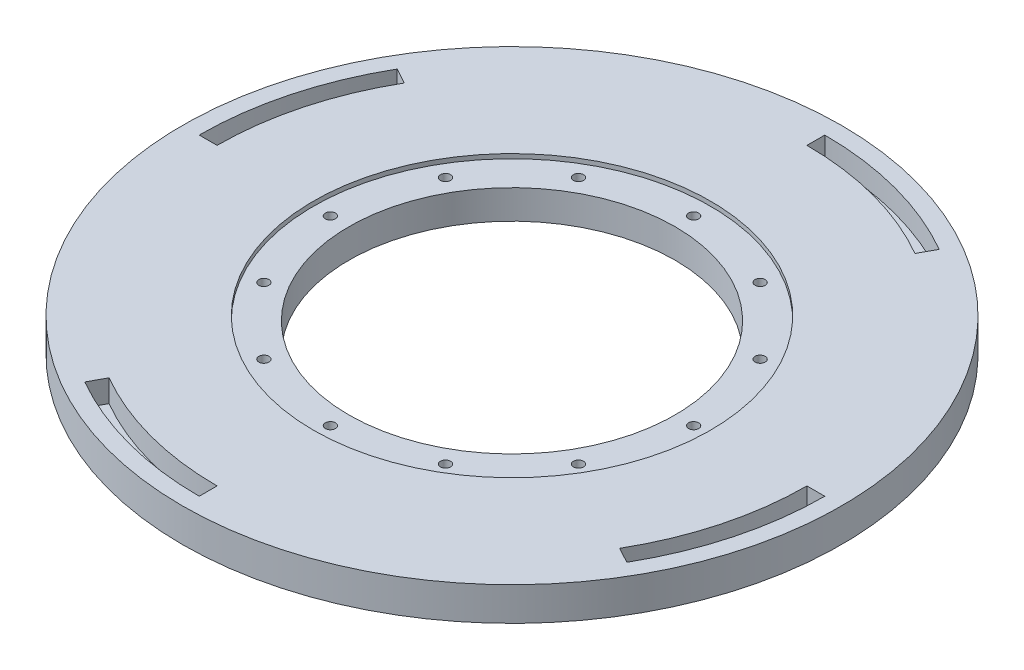
from build123d import *

# Parameters (mm, degrees)
SKETCH1_W                   = 127.635
SKETCH1_H                   = 127.635
BOSS_EXTRUDE1_DEPTH         = 9.525
SKETCH13_R                  = 93.6625
BOSS_EXTRUDE2_DEPTH         = 9.525
SKETCH5_R                   = 46.355
CUT_EXTRUDE1_DEPTH          = 9.525
SKETCH11_R                  = 1.4351
CUT_EXTRUDE3_DEPTH          = 10.525
CIRPATTERN1_COUNT           = 12
SKETCH12_R                  = 56.41975
CUT_EXTRUDE4_DEPTH          = 1.27
SUPPORT_HOLE_DEPTH          = 6.35
SKETCH16_R                  = 1.27
FRAME_BOLT_HOLE_DEPTH       = 3.175
FRAME_SUPPORT_PATTERN_COUNT = 4


with BuildPart() as part:
    # Sketch1 → Boss-Extrude1 (new body)
    with BuildSketch(Plane(origin=(0, 0, 0), x_dir=(1, 0, 0), z_dir=(0, 1, 0))):
        with Locations((63.8175, 63.8175)):
            Rectangle(SKETCH1_W, SKETCH1_H)
    extrude(amount=BOSS_EXTRUDE1_DEPTH)

    # Sketch13 → Boss-Extrude2 (add)
    with BuildSketch(Plane(origin=(0, 9.525, 0), x_dir=(1, 0, 0), z_dir=(0, 1, 0))):
        with Locations((63.8175, 63.8175)):
            Circle(SKETCH13_R)
    extrude(amount=-BOSS_EXTRUDE2_DEPTH)

    # Sketch5 → Cut-Extrude1 (cut)
    with BuildSketch(Plane(origin=(0, 9.525, 0), x_dir=(1, 0, 0), z_dir=(0, 1, 0))):
        with Locations((63.8175, 63.8175)):
            Circle(SKETCH5_R)
    extrude(amount=-CUT_EXTRUDE1_DEPTH, mode=Mode.SUBTRACT)

    # Sketch11 → Cut-Extrude3 (cut, through all)
    with BuildSketch(Plane(origin=(0, 9.525, 0), x_dir=(1, 0, 0), z_dir=(0, 1, 0))):
        with Locations((63.8175, 115.443)):
            Circle(SKETCH11_R)
    cut_extrude3 = extrude(amount=-CUT_EXTRUDE3_DEPTH, mode=Mode.SUBTRACT)

    # CirPattern1: Cut-Extrude3 ×12 about axis
    cirpattern1_axis = Axis((63.8175, 0, -63.8175), (0, 1, 0))
    for i in range(1, CIRPATTERN1_COUNT):
        add(cut_extrude3.rotate(cirpattern1_axis, i * 360 / CIRPATTERN1_COUNT), mode=Mode.SUBTRACT)

    # Sketch12 → Cut-Extrude4 (cut)
    with BuildSketch(Plane(origin=(0, 9.525, 0), x_dir=(1, 0, 0), z_dir=(0, 1, 0))):
        with Locations((63.8175, 63.8175)):
            Circle(SKETCH12_R)
    extrude(amount=-CUT_EXTRUDE4_DEPTH, mode=Mode.SUBTRACT)

    # Sketch15 → Support hole (cut)
    with BuildSketch(Plane(origin=(0, 9.525, 0), x_dir=(1, 0, 0), z_dir=(0, 1, 0))):
        with BuildLine():
            Line((-20.0025, 63.8175), (-25.0825, 63.8175))
            ThreePointArc((-25.0825, 63.8175), (-22.061832172, 86.794669228), (-13.205102796, 108.21038973))
            Line((-13.205102796, 108.21038973), (-8.745758996, 105.774213931))
            ThreePointArc((-8.745758996, 105.774213931), (-17.139416842, 85.53776739), (-20.0025, 63.8175))
        make_face()
    support_hole = extrude(amount=-SUPPORT_HOLE_DEPTH, mode=Mode.SUBTRACT)

    # Sketch16 → Frame bolt hole (cut)
    with BuildSketch(Plane(origin=(0, 0, 0), x_dir=(-1, 0, 0), z_dir=(0, -1, 0))):
        with Locations((19.592656746, 86.195957311)):
            Circle(SKETCH16_R)
    frame_bolt_hole = extrude(amount=-FRAME_BOLT_HOLE_DEPTH, mode=Mode.SUBTRACT)

    # Frame support pattern: Support hole, Frame bolt hole ×4 about axis
    frame_support_pattern_axis = Axis((63.8175, 0, -63.8175), (0, 1, 0))
    for i in range(1, FRAME_SUPPORT_PATTERN_COUNT):
        add(support_hole.rotate(frame_support_pattern_axis, i * 360 / FRAME_SUPPORT_PATTERN_COUNT), mode=Mode.SUBTRACT)
        add(frame_bolt_hole.rotate(frame_support_pattern_axis, i * 360 / FRAME_SUPPORT_PATTERN_COUNT), mode=Mode.SUBTRACT)


solid = part.part
